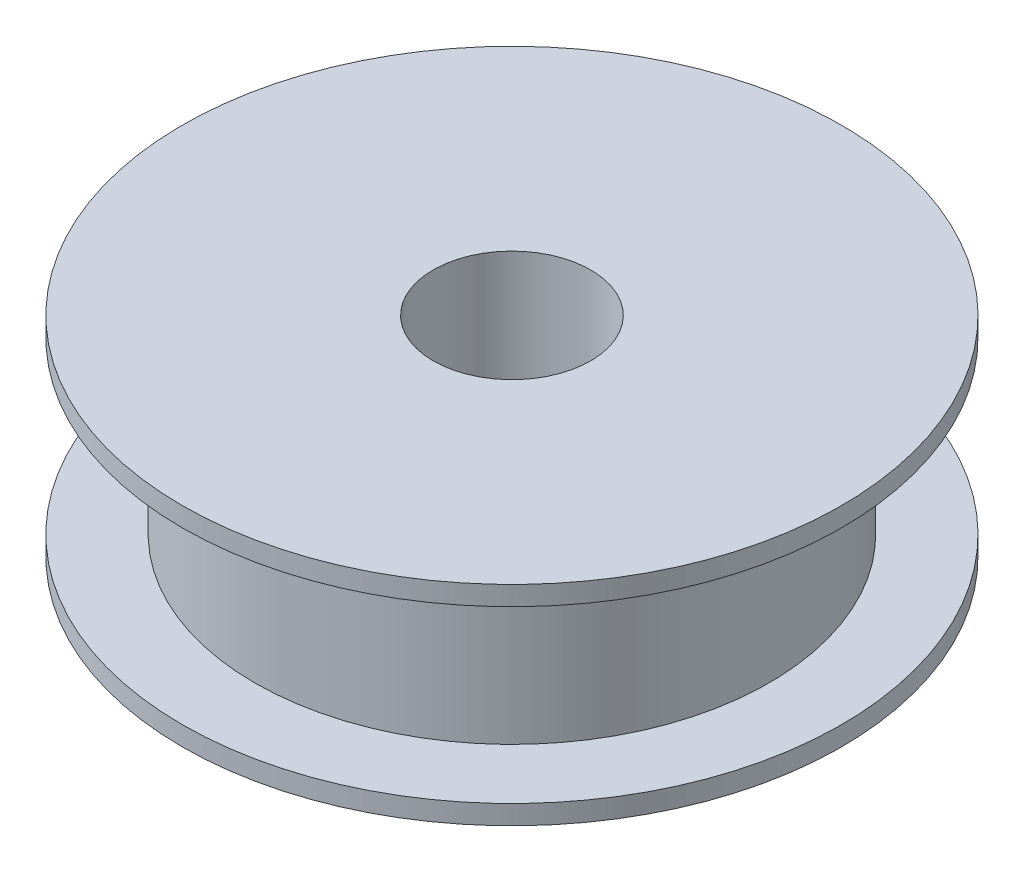
from build123d import *


with BuildPart() as part:
    # Esboço1 → Revolução1 (revolve)
    with BuildSketch(Plane.XY):
        Polygon((24.5, 0), (102.5, 0), (102.5, 6), (80, 6), (80, 59), (102.5, 59), (102.5, 65), (24.5, 65), align=None)
    revolve(axis=Axis((0, 29.989278224, 0), (0, -1, 0)))


solid = part.part
